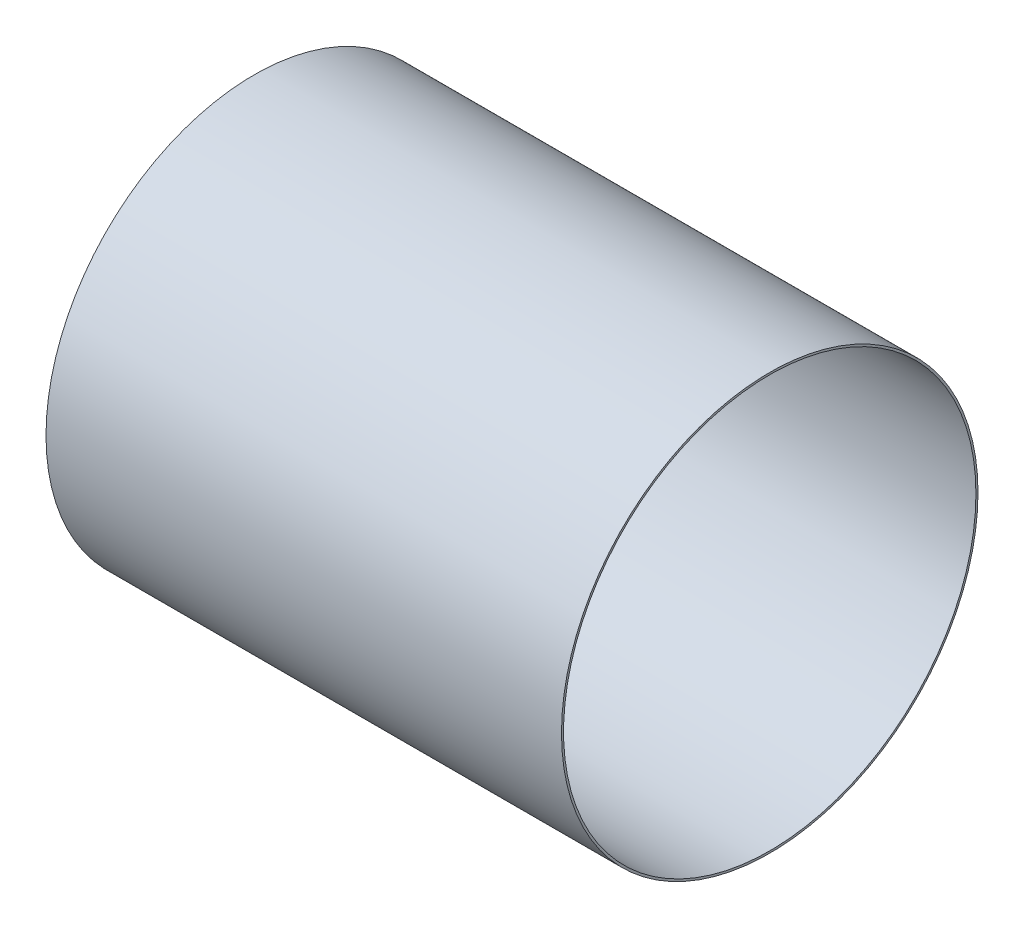
from build123d import *

# Parameters (mm, degrees)
SKETCH1_W          = 250
SKETCH1_H          = 101
SKETCH2_R          = 100
CUT_EXTRUDE2_DEPTH = 250


with BuildPart() as part:
    # Sketch1 → Revolve1 (revolve)
    with BuildSketch(Plane.XY):
        with Locations((125, 50.5)):
            Rectangle(SKETCH1_W, SKETCH1_H)
    revolve(axis=Axis((0, 101, 0), (1, 0, 0)))

    # Sketch2 → Cut-Extrude2 (cut)
    with BuildSketch(Plane(origin=(250, 0, 0), x_dir=(0, 0, -1), z_dir=(1, 0, 0))):
        with Locations((0, 101)):
            Circle(SKETCH2_R)
    extrude(amount=-CUT_EXTRUDE2_DEPTH, mode=Mode.SUBTRACT)


solid = part.part
